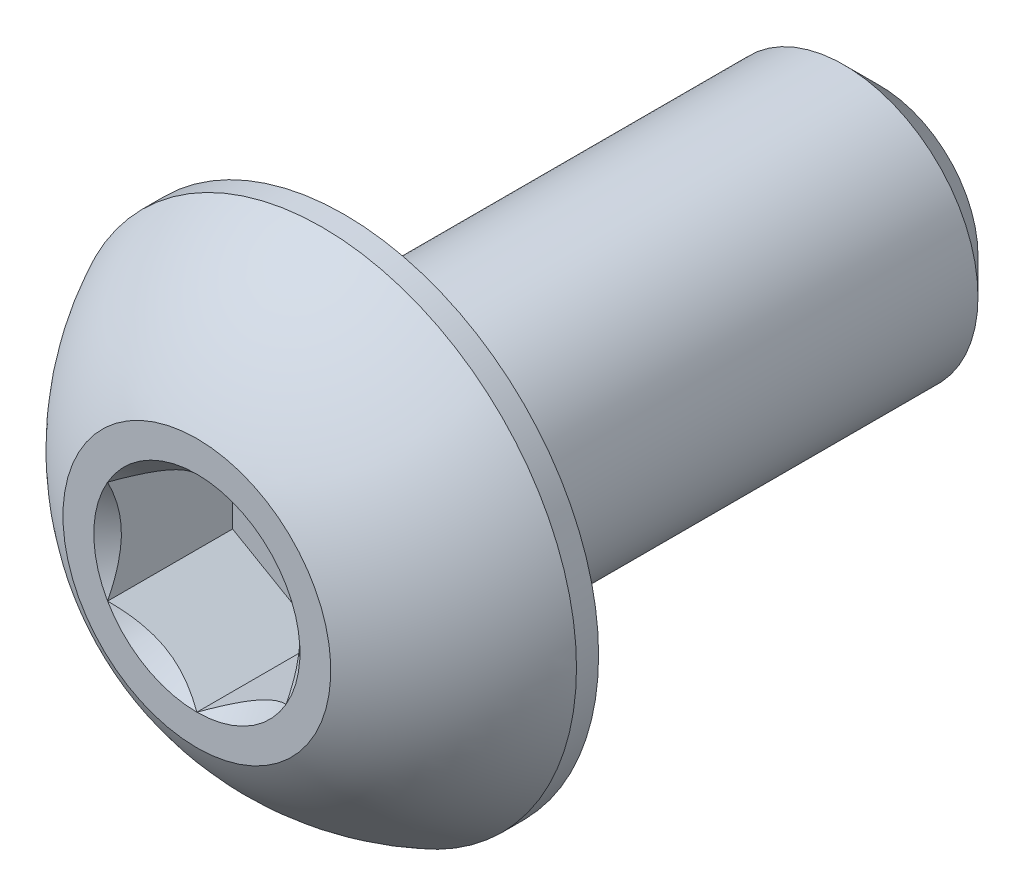
from build123d import *

# Parameters (mm, degrees)
CUT_EXTRUDE1_DEPTH = 1.4


with BuildPart() as part:
    # Sketch2 → Revolve1 (revolve)
    with BuildSketch(Plane(origin=(0, 0, 0), x_dir=(0, 0, -1), z_dir=(1, 0, 0)), mode=Mode.PRIVATE) as revolve1_sk:
        with BuildLine():
            Line((-3.825, 0), (3.825, 0))
            Line((3.825, 0), (3.825, 1.1))
            Line((3.825, 1.1), (3.425, 1.5))
            Line((3.425, 1.5), (-2.175, 1.5))
            Line((-2.175, 1.5), (-2.175, 2.85))
            Line((-2.175, 2.85), (-2.4225, 2.85))
            ThreePointArc((-2.4225, 2.85), (-3.22987489, 2.285251969), (-3.825, 1.5))
            Line((-3.825, 1.5), (-3.825, 0))
        make_face()
    revolve(revolve1_sk.sketch.rotate(Axis((0, 0, 3.825), (0, 0, -1)), 90), axis=Axis((0, 0, 3.825), (0, 0, -1)))

    # Sketch3 → Cut-Extrude1 (cut)
    with BuildSketch(Plane.XY.offset(3.825)):
        Polygon((0, 1.154700538), (-1, 0.577350269), (-1, -0.577350269), (0, -1.154700538), (1, -0.577350269), (1, 0.577350269), align=None)
    extrude(amount=-CUT_EXTRUDE1_DEPTH, mode=Mode.SUBTRACT)

    # Cut-Extrude2 cone 1 section (through the dimple's axis) → Cut-Extrude2 (revolve, cut)
    with BuildSketch(Plane(origin=(0, 0, 3.825), x_dir=(0, -1, 0), z_dir=(1, 0, 0))):
        Polygon((0, 0), (1.154700538, 0), (0, 1.154700538), align=None)
    revolve(axis=Axis((0, 0, 3.825), (0, 0, -1)), mode=Mode.SUBTRACT)


solid = part.part
